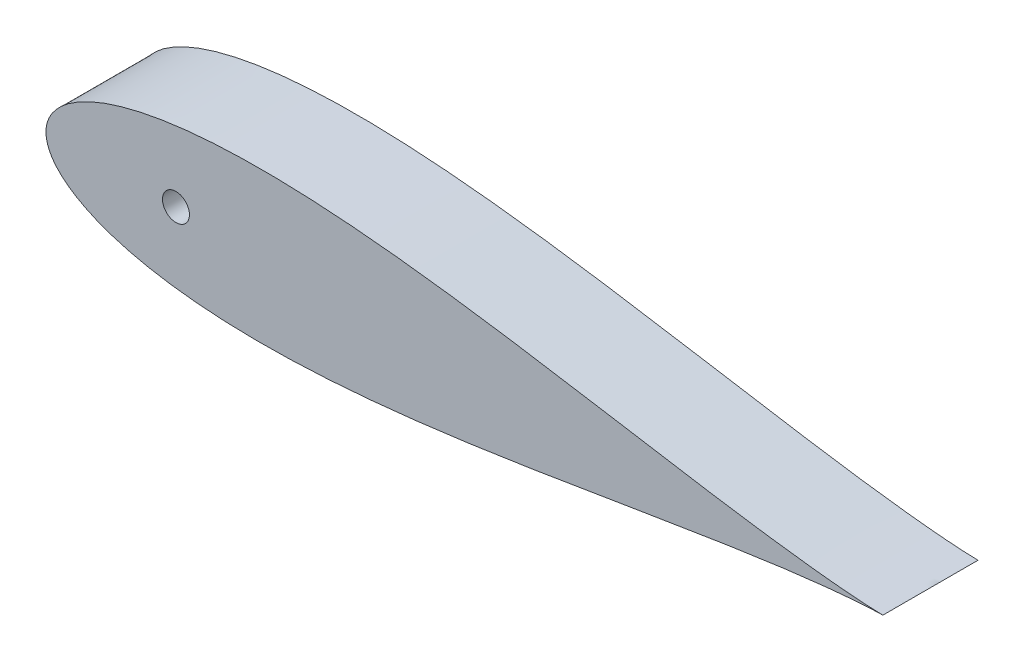
from build123d import *

# Parameters (mm, degrees)
BOSS_EXTRUDE1_DEPTH     = 76.2
SKETCH3_R               = 10.795
CUT_EXTRUDE2_DEPTH      = 76.2
SKETCH6_R               = 6.35
CUT_EXTRUDE3_DEPTH      = 53.34
CUT_EXTRUDE3_DEPTH_BACK = 0.000254


with BuildPart() as part:
    # Sketch1 → Boss-Extrude1 (new body)
    with BuildSketch(Plane.XY):
        with BuildLine():
            Line((643.966787522, 0), (643.599082689, 0))
            Line((643.599082689, 0), (643.599082689, -1.016))
            ThreePointArc((643.599082689, -1.016), (643.872033494, -0.540245973), (643.966787522, 0))
        make_face()
        with BuildLine():
            Line((643.599082689, -1.016), (643.599082689, 0))
            Line((643.599082689, 0), (641.567082689, 0))
            ThreePointArc((641.567082689, 0), (642.269121423, -1.135922533), (643.599082689, -1.016))
        make_face()
        with BuildLine():
            Line((641.567082689, 0), (643.599082689, 0))
            Line((643.599082689, 0), (643.966787522, 0))
            ThreePointArc((643.966787522, 0), (643.547407924, 1.075012082), (642.510849283, 1.582039112))
            add(Edge.make_bspline(
                [(642.510849283, 1.582039112), (641.993392355, 1.625070631), (638.093728429, 1.953546407), (630.413817462, 2.663385493), (619.014124193, 3.849253664), (606.374988512, 5.304428983), (592.543922516, 7.037634907), (577.585454095, 9.050636147), (561.564270734, 11.338919625), (544.549749946, 13.890665375), (526.614143658, 16.687720753), (507.832591566, 19.705111663), (488.282710288, 22.911672601), (468.044367735, 26.27043606), (447.199424328, 29.739007432), (425.831595832, 33.270324121), (404.02631566, 36.813220545), (381.870662856, 40.313266856), (359.453314895, 43.713502532), (336.86454415, 46.955447457), (314.196207315, 49.979843895), (291.541767704, 52.727712704), (268.996310773, 55.141201012), (246.65655865, 57.164603829), (224.620860897, 58.745176641), (202.989192599, 59.8341217), (181.863132616, 60.387506142), (161.345829027, 60.366961324), (141.542033828, 59.739895824), (122.558104573, 58.481758104), (104.502313427, 56.574303932), (87.485018636, 54.008935199), (71.619696083, 50.784752003), (57.023709725, 46.912543066), (43.82045433, 42.41500246), (32.141645239, 37.332204029), (22.129107375, 31.731455339), (13.932423524, 25.726412106), (7.689616489, 19.513207632), (3.463136343, 13.420354421), (1.106333228, 7.923389435), (0.154611582, 3.513796615), (0, 1.007496172), (0, 0)],
                knots=[0.020157042, 0.020157042, 0.020157042, 0.020157042, 0.021270888, 0.028552555, 0.036780684, 0.045920102, 0.055931764, 0.066772884, 0.07839713, 0.090754827, 0.103793165, 0.117456432, 0.131686226, 0.146421738, 0.161599998, 0.177156133, 0.193023668, 0.209134786, 0.225420633, 0.241811602, 0.258237647, 0.274628557, 0.290914287, 0.307025229, 0.322892517, 0.338448342, 0.353626207, 0.368361232, 0.382590428, 0.396252961, 0.409290412, 0.42164701, 0.433269881, 0.444109249, 0.45411864, 0.463255055, 0.471479114, 0.478755289, 0.485052318, 0.490344026, 0.494609833, 0.497833231, 0.5, 0.5, 0.5, 0.5], degree=3))
            Line((0, 0), (27.94, 0))
            ThreePointArc((27.94, 0), (40.64, 12.7), (53.34, 0))
            Line((53.34, 0), (93.345, 0))
            ThreePointArc((93.345, 0), (104.14, 10.795), (114.935, 0))
            Line((114.935, 0), (460.660965279, 0))
            Line((460.660965279, 0), (473.360965279, 0))
            Line((473.360965279, 0), (641.567082689, 0))
        make_face()
        with BuildLine():
            ThreePointArc((642.510849283, -1.582039112), (643.111845681, -1.408373102), (643.599082689, -1.016))
            ThreePointArc((643.599082689, -1.016), (642.269121423, -1.135922533), (641.567082689, 0))
            Line((641.567082689, 0), (473.360965279, 0))
            Line((473.360965279, 0), (460.660965279, 0))
            Line((460.660965279, 0), (114.935, 0))
            ThreePointArc((114.935, 0), (104.14, -10.795), (93.345, 0))
            Line((93.345, 0), (53.34, 0))
            ThreePointArc((53.34, 0), (40.64, -12.7), (27.94, 0))
            Line((27.94, 0), (0, 0))
            add(Edge.make_bspline(
                [(0, 0), (0, -1.007496172), (0.154611582, -3.513796615), (1.106333228, -7.923389435), (3.463136343, -13.420354421), (7.689616489, -19.513207632), (13.932423524, -25.726412106), (22.129107375, -31.731455339), (32.141645239, -37.332204029), (43.82045433, -42.41500246), (57.023709725, -46.912543066), (71.619696083, -50.784752003), (87.485018636, -54.008935199), (104.502313427, -56.574303932), (122.558104573, -58.481758104), (141.542033828, -59.739895824), (161.345829027, -60.366961324), (181.863132616, -60.387506142), (202.989192599, -59.8341217), (224.620860897, -58.745176641), (246.65655865, -57.164603829), (268.996310773, -55.141201012), (291.541767704, -52.727712704), (314.196207315, -49.979843895), (336.86454415, -46.955447457), (359.453314895, -43.713502532), (381.870662856, -40.313266856), (404.02631566, -36.813220545), (425.831595832, -33.270324121), (447.199424328, -29.739007432), (468.044367735, -26.27043606), (488.282710288, -22.911672601), (507.832591566, -19.705111663), (526.614143658, -16.687720753), (544.549749946, -13.890665375), (561.564270734, -11.338919625), (577.585454095, -9.050636147), (592.543922516, -7.037634907), (606.374988512, -5.304428983), (619.014124193, -3.849253664), (630.413817462, -2.663385493), (638.093728429, -1.953546407), (641.993392355, -1.625070631), (642.510849283, -1.582039112)],
                knots=[0.5, 0.5, 0.5, 0.5, 0.502166769, 0.505390167, 0.509655974, 0.514947682, 0.521244711, 0.528520886, 0.536744945, 0.54588136, 0.555890751, 0.566730119, 0.57835299, 0.590709588, 0.603747039, 0.617409572, 0.631638768, 0.646373793, 0.661551658, 0.677107483, 0.692974771, 0.709085713, 0.725371443, 0.741762353, 0.758188398, 0.774579367, 0.790865214, 0.806976332, 0.822843867, 0.838400002, 0.853578262, 0.868313774, 0.882543568, 0.896206835, 0.909245173, 0.92160287, 0.933227116, 0.944068236, 0.954079898, 0.963219316, 0.971447445, 0.978729112, 0.979842958, 0.979842958, 0.979842958, 0.979842958], degree=3))
        make_face()
        with BuildLine():
            ThreePointArc((643.966787522, 0), (643.872033494, -0.540245973), (643.599082689, -1.016))
            ThreePointArc((643.599082689, -1.016), (643.111845681, -1.408373102), (642.510849283, -1.582039112))
            add(Edge.make_bspline(
                [(642.510849283, -1.582039112), (644.922074617, -1.381522545), (649.798936594, -1.000308437), (656.504964311, -0.543558383), (662.850933168, -0.234427605), (666.344759683, -0.054696708), (670.56, -0.015678595), (670.56, 0)],
                knots=[0.979842958, 0.979842958, 0.979842958, 0.979842958, 0.985033212, 0.990332793, 0.994605218, 0.997832222, 1, 1, 1, 1], degree=3))
            add(Edge.make_bspline(
                [(670.56, 0), (670.56, 0.015678595), (666.344759683, 0.054696708), (662.850933168, 0.234427605), (656.504964311, 0.543558383), (649.798936594, 1.000308437), (644.922074617, 1.381522545), (642.510849283, 1.582039112)],
                knots=[0, 0, 0, 0, 0.002167778, 0.005394782, 0.009667207, 0.014966788, 0.020157042, 0.020157042, 0.020157042, 0.020157042], degree=3))
            ThreePointArc((642.510849283, 1.582039112), (643.547407924, 1.075012082), (643.966787522, 0))
        make_face()
        with BuildLine():
            ThreePointArc((53.34, 0), (40.64, 12.7), (27.94, 0))
            Line((27.94, 0), (53.34, 0))
        make_face()
        with BuildLine():
            Line((53.34, 0), (27.94, 0))
            ThreePointArc((27.94, 0), (40.64, -12.7), (53.34, 0))
        make_face()
        with BuildLine():
            ThreePointArc((93.345, 0), (104.14, -10.795), (114.935, 0))
            Line((114.935, 0), (93.345, 0))
        make_face()
        with BuildLine():
            Line((93.345, 0), (114.935, 0))
            ThreePointArc((114.935, 0), (104.14, 10.795), (93.345, 0))
        make_face()
    extrude(amount=BOSS_EXTRUDE1_DEPTH)

    # Sketch3 → Cut-Extrude2 (cut)
    with BuildSketch(Plane.XY.offset(76.2)):
        with Locations((104.139232412, 0)):
            Circle(SKETCH3_R)
    extrude(amount=-CUT_EXTRUDE2_DEPTH, mode=Mode.SUBTRACT)

    # Sketch6 → Cut-Extrude3 (cut, two sides)
    with BuildSketch(Plane(origin=(0, 0, 0), x_dir=(0, 0, -1), z_dir=(1, 0, 0))) as cut_extrude3_sk:
        with Locations((-20.32, 0)):
            Circle(SKETCH6_R)
    extrude(amount=CUT_EXTRUDE3_DEPTH, mode=Mode.SUBTRACT)
    extrude(cut_extrude3_sk.sketch, amount=-CUT_EXTRUDE3_DEPTH_BACK, mode=Mode.SUBTRACT)


solid = part.part
